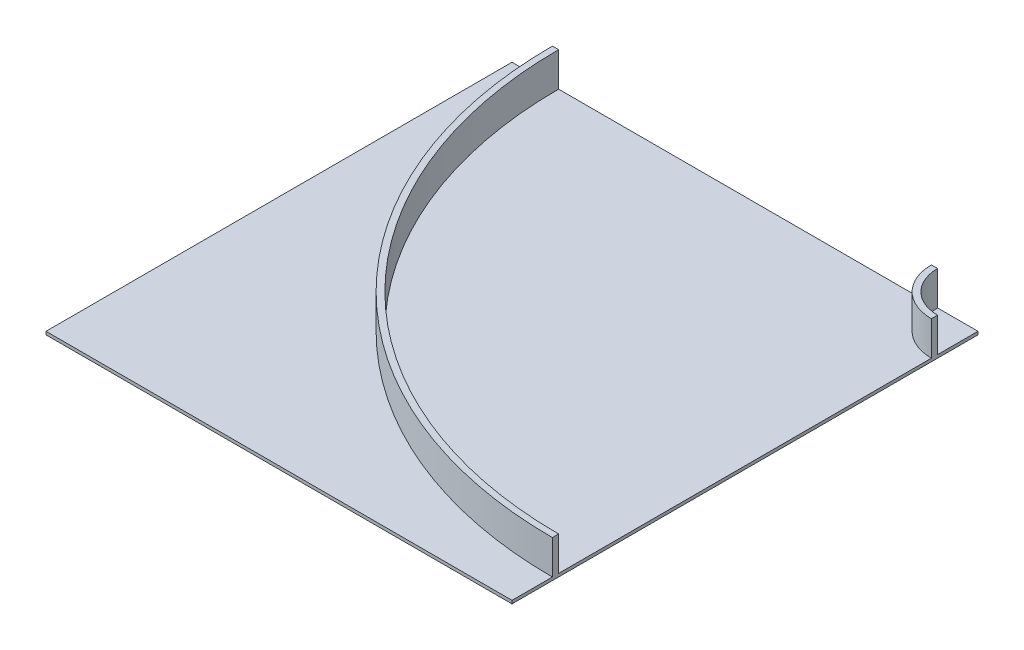
from build123d import *

# Parameters (mm, degrees)
SKETCH2_W           = 1500
SKETCH2_H           = 1500
BOSS_EXTRUDE1_DEPTH = 10
BOSS_EXTRUDE2_DEPTH = 110


with BuildPart() as part:
    # Sketch2 → Boss-Extrude1 (new body)
    with BuildSketch(Plane(origin=(0, 0, 0), x_dir=(1, 0, 0), z_dir=(0, 1, 0))):
        Rectangle(SKETCH2_W, SKETCH2_H)
    extrude(amount=BOSS_EXTRUDE1_DEPTH)

    # Sketch3 → Boss-Extrude2 (add)
    with BuildSketch(Plane(origin=(0, 10, 0), x_dir=(1, 0, 0), z_dir=(0, 1, 0))):
        with BuildLine():
            ThreePointArc((750, -600), (-204.594154602, -204.594154602), (-600, 750))
            Line((-600, 750), (-620, 750))
            ThreePointArc((-620, 750), (-218.736290226, -218.736290226), (750, -620))
            Line((750, -620), (750, -600))
        make_face()
        with BuildLine():
            Line((620, 750), (600, 750))
            ThreePointArc((600, 750), (643.933982822, 643.933982822), (750, 600))
            Line((750, 600), (750, 620))
            ThreePointArc((750, 620), (658.076118446, 658.076118446), (620, 750))
        make_face()
    extrude(amount=BOSS_EXTRUDE2_DEPTH)


solid = part.part
